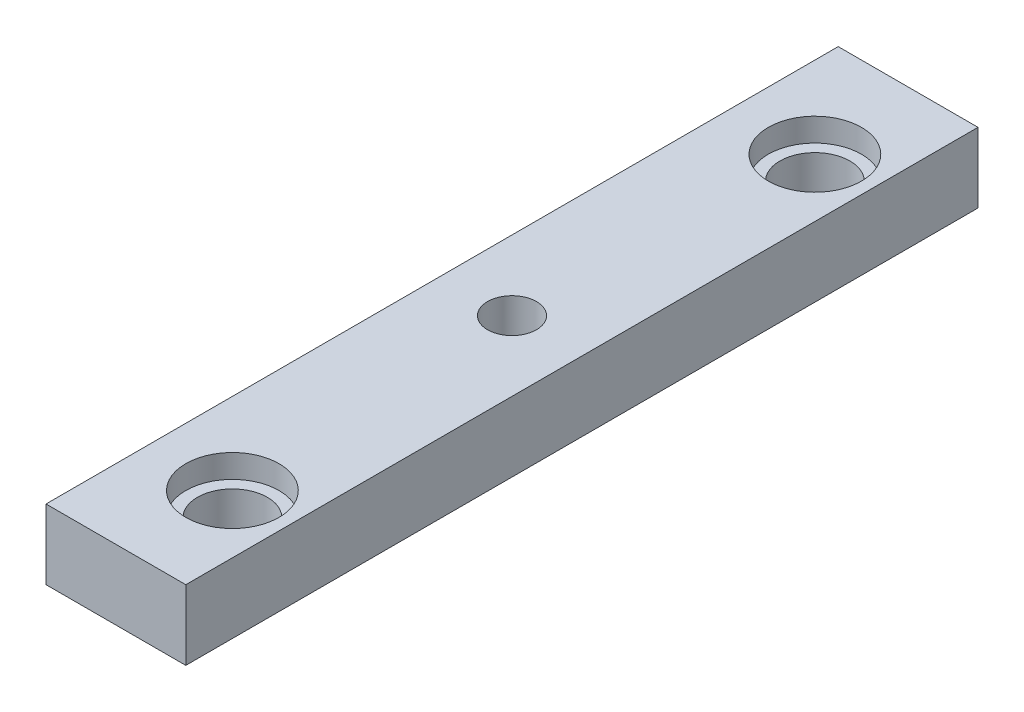
from build123d import *

# Parameters (mm, degrees)
SKETCH1_W             = 12
SKETCH1_H             = 6
BOSS_EXTRUDE1_DEPTH   = 60
SKETCH2_R             = 3
CUT_EXTRUDE1_DEPTH    = 7
SKETCH3_R             = 4
CUT_EXTRUDE2_DEPTH    = 2
SKETCH4_W             = 12
SKETCH4_H             = 6
BOSS_EXTRUDE2_DEPTH   = 4
SKETCH5_W             = 12
SKETCH5_H             = 6
BOSS_EXTRUDE3_DEPTH   = 4
M5_TAPPED_HOLE1_D     = 4.2
M5_TAPPED_HOLE1_DEPTH = 52
M5_TAPPED_HOLE1_TIP   = 1.2618073


with BuildPart() as part:
    # Sketch1 → Boss-Extrude1 (new body)
    with BuildSketch(Plane.XY):
        Rectangle(SKETCH1_W, SKETCH1_H)
    extrude(amount=BOSS_EXTRUDE1_DEPTH)

    # Sketch2 → Cut-Extrude1 (cut, through all)
    with BuildSketch(Plane(origin=(0, 3, 0), x_dir=(1, 0, 0), z_dir=(0, 1, 0))):
        with Locations((1, -5)):
            Circle(SKETCH2_R)
        with Locations((1, -55)):
            Circle(SKETCH2_R)
    extrude(amount=-CUT_EXTRUDE1_DEPTH, mode=Mode.SUBTRACT)

    # Sketch3 → Cut-Extrude2 (cut)
    with BuildSketch(Plane(origin=(0, 3, 0), x_dir=(1, 0, 0), z_dir=(0, 1, 0))):
        with Locations((1, -5)):
            Circle(SKETCH3_R)
        with Locations((1, -55)):
            Circle(SKETCH3_R)
    extrude(amount=-CUT_EXTRUDE2_DEPTH, mode=Mode.SUBTRACT)

    # Sketch4 → Boss-Extrude2 (add)
    with BuildSketch(Plane(origin=(0, 0, 0), x_dir=(-1, 0, 0), z_dir=(0, 0, -1))):
        Rectangle(SKETCH4_W, SKETCH4_H)
    extrude(amount=BOSS_EXTRUDE2_DEPTH)

    # Sketch5 → Boss-Extrude3 (add)
    with BuildSketch(Plane.XY.offset(60)):
        Rectangle(SKETCH5_W, SKETCH5_H)
    extrude(amount=BOSS_EXTRUDE3_DEPTH)

    # M5 Tapped Hole1
    with Locations(Plane(origin=(0, 3, 0), x_dir=(-1, 0, 0), z_dir=(0, 1, 0))):
        with Locations((0, 30)):
            Hole(M5_TAPPED_HOLE1_D / 2, depth=M5_TAPPED_HOLE1_DEPTH)
            with Locations((0, 0, -(M5_TAPPED_HOLE1_DEPTH + M5_TAPPED_HOLE1_TIP / 2))):  # 118° drill point
                Cone(0, M5_TAPPED_HOLE1_D / 2, M5_TAPPED_HOLE1_TIP, mode=Mode.SUBTRACT)


solid = part.part
